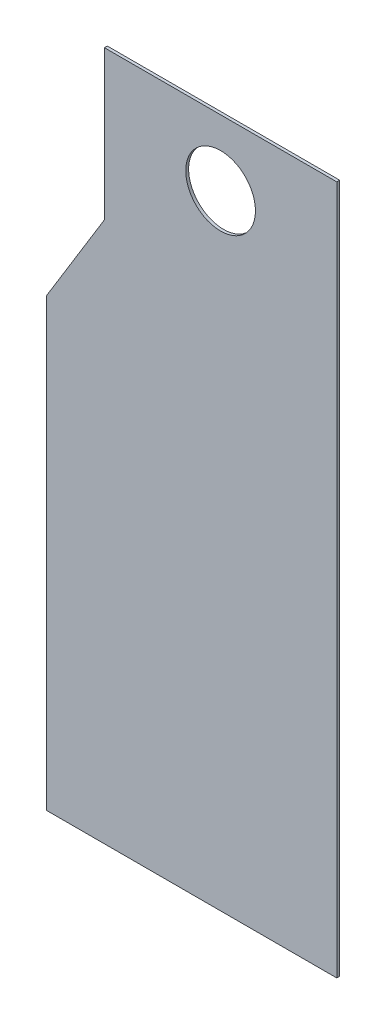
from build123d import *

# Parameters (mm, degrees)
SKETCH1_R           = 36
BOSS_EXTRUDE1_DEPTH = 3


with BuildPart() as part:
    # Sketch1 → Boss-Extrude1 (new body)
    with BuildSketch(Plane.XY):
        Polygon((0, 0), (0, 154), (240, 154), (240, -558), (-60, -558), (-60, -98), align=None)
        with Locations((120, 86)):
            Circle(SKETCH1_R, mode=Mode.SUBTRACT)
    extrude(amount=BOSS_EXTRUDE1_DEPTH)


solid = part.part
